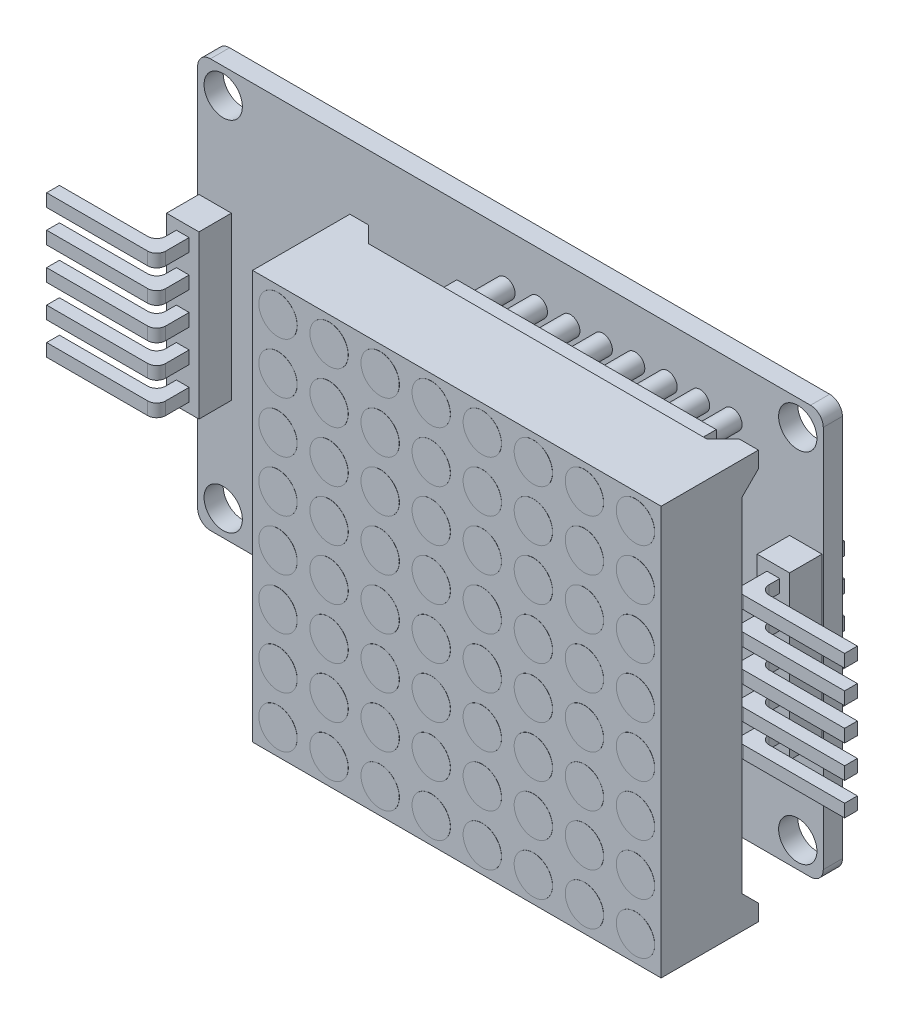
from build123d import *

# Parameters (mm, degrees)
CROQUIS1_R                = 1.5
SALIENTE_EXTRUIR1_DEPTH   = 1.5
CROQUIS2_W                = 2.54
CROQUIS2_H                = 12.7
SALIENTE_EXTRUIR2_DEPTH   = 2.54
CROQUIS3_R                = 0.75
SALIENTE_EXTRUIR3_DEPTH   = 2.54
CROQUIS4_W                = 20.32
CROQUIS4_H                = 2.4
SALIENTE_EXTRUIR4_DEPTH   = 2.54
CROQUIS5_R                = 0.5
CORTAR_EXTRUIR1_DEPTH     = 1.27
SALIENTE_EXTRUIR6_START   = -5.08
CROQUIS6_W                = 1
CROQUIS6_H                = 1
SALIENTE_EXTRUIR6_DEPTH   = 7.62
CROQUIS8_W                = 1
CROQUIS8_H                = 1
SALIENTE_EXTRUIR7_DEPTH   = 7.62
REDONDEO3_R               = 0.7
REDONDEO4_R               = 0.7
REDONDEO5_R               = 0.7
REDONDEO6_R               = 0.7
REDONDEO7_R               = 0.7
REDONDEO8_R               = 0.7
REDONDEO9_R               = 0.7
REDONDEO10_R              = 0.7
REDONDEO11_R              = 0.7
REDONDEO12_R              = 0.7
REDONDEO3_OF_SIMETR_A1_R  = 0.7
REDONDEO4_OF_SIMETR_A1_R  = 0.7
REDONDEO5_OF_SIMETR_A1_R  = 0.7
REDONDEO6_OF_SIMETR_A1_R  = 0.7
REDONDEO7_OF_SIMETR_A1_R  = 0.7
REDONDEO8_OF_SIMETR_A1_R  = 0.7
REDONDEO9_OF_SIMETR_A1_R  = 0.7
REDONDEO10_OF_SIMETR_A1_R = 0.7
REDONDEO11_OF_SIMETR_A1_R = 0.7
REDONDEO12_OF_SIMETR_A1_R = 0.7
CROQUIS11_W               = 32
CROQUIS11_H               = 32
SALIENTE_EXTRUIR8_DEPTH   = 7.62
CROQUIS12_W               = 31.6
CROQUIS12_H               = 31.6
CORTAR_EXTRUIR2_DEPTH     = 5.08
CORTAR_EXTRUIR5_DEPTH     = 0.2
CORTAR_EXTRUIR7_DEPTH     = 2.3
CORTAR_EXTRUIR8_DEPTH     = 2.3
CORTAR_EXTRUIR9_DEPTH     = 2.3
CROQUIS18_R               = 1.5
SALIENTE_EXTRUIR9_DEPTH   = 0.01


with BuildPart() as part:
    # Croquis1 → Saliente-Extruir1 (new body)
    with BuildSketch(Plane.XY):
        with BuildLine():
            Line((-23.5, 16), (23.5, 16))
            ThreePointArc((23.5, 16), (24.207106781, 15.707106781), (24.5, 15))
            Line((24.5, 15), (24.5, -15))
            ThreePointArc((24.5, -15), (24.207106781, -15.707106781), (23.5, -16))
            Line((23.5, -16), (-23.5, -16))
            ThreePointArc((-23.5, -16), (-24.207106781, -15.707106781), (-24.5, -15))
            Line((-24.5, -15), (-24.5, 15))
            ThreePointArc((-24.5, 15), (-24.207106781, 15.707106781), (-23.5, 16))
        make_face()
        with Locations((-22.5, -14)):
            Circle(CROQUIS1_R, mode=Mode.SUBTRACT)
        with Locations((-22.5, 14)):
            Circle(CROQUIS1_R, mode=Mode.SUBTRACT)
        with Locations((22.5, 14)):
            Circle(CROQUIS1_R, mode=Mode.SUBTRACT)
        with Locations((22.5, -14)):
            Circle(CROQUIS1_R, mode=Mode.SUBTRACT)
    extrude(amount=SALIENTE_EXTRUIR1_DEPTH)

    # Croquis2 → Saliente-Extruir2 (add)
    with BuildSketch(Plane.XY.offset(1.5)):
        with Locations((-23.13, 0)):
            Rectangle(CROQUIS2_W, CROQUIS2_H)
        with Locations((23.13, 0)):
            Rectangle(CROQUIS2_W, CROQUIS2_H)
    extrude(amount=SALIENTE_EXTRUIR2_DEPTH)

    # Croquis3 → Saliente-Extruir3 (add, symmetric)
    with BuildSketch(Plane.XY.offset(1.5)):
        with Locations((-0.39, 12)):
            Circle(CROQUIS3_R)
        with Locations((2.15, 12)):
            Circle(CROQUIS3_R)
        with Locations((4.69, 12)):
            Circle(CROQUIS3_R)
        with Locations((7.23, 12)):
            Circle(CROQUIS3_R)
        with Locations((9.77, 12)):
            Circle(CROQUIS3_R)
        with Locations((12.31, 12)):
            Circle(CROQUIS3_R)
        with Locations((14.85, 12)):
            Circle(CROQUIS3_R)
        with Locations((17.39, 12)):
            Circle(CROQUIS3_R)
        with Locations((17.39, -12)):
            Circle(CROQUIS3_R)
        with Locations((14.85, -12)):
            Circle(CROQUIS3_R)
        with Locations((12.31, -12)):
            Circle(CROQUIS3_R)
        with Locations((9.77, -12)):
            Circle(CROQUIS3_R)
        with Locations((7.23, -12)):
            Circle(CROQUIS3_R)
        with Locations((4.69, -12)):
            Circle(CROQUIS3_R)
        with Locations((2.15, -12)):
            Circle(CROQUIS3_R)
        with Locations((-0.39, -12)):
            Circle(CROQUIS3_R)
    extrude(amount=SALIENTE_EXTRUIR3_DEPTH, both=True)

    # Croquis4 → Saliente-Extruir4 (add)
    with BuildSketch(Plane.XY.offset(4.04)):
        with Locations((8.5, 12)):
            Rectangle(CROQUIS4_W, CROQUIS4_H)
        with Locations((8.5, -12)):
            Rectangle(CROQUIS4_W, CROQUIS4_H)
    extrude(amount=SALIENTE_EXTRUIR4_DEPTH)

    # Croquis5 → Cortar-Extruir1 (cut)
    with BuildSketch(Plane.XY.offset(6.58)):
        with Locations((-0.39, 12)):
            Circle(CROQUIS5_R)
        with Locations((2.15, 12)):
            Circle(CROQUIS5_R)
        with Locations((4.69, 12)):
            Circle(CROQUIS5_R)
        with Locations((7.23, 12)):
            Circle(CROQUIS5_R)
        with Locations((9.77, 12)):
            Circle(CROQUIS5_R)
        with Locations((12.31, 12)):
            Circle(CROQUIS5_R)
        with Locations((14.85, 12)):
            Circle(CROQUIS5_R)
        with Locations((17.39, 12)):
            Circle(CROQUIS5_R)
        with Locations((17.39, -12)):
            Circle(CROQUIS5_R)
        with Locations((14.85, -12)):
            Circle(CROQUIS5_R)
        with Locations((12.31, -12)):
            Circle(CROQUIS5_R)
        with Locations((9.77, -12)):
            Circle(CROQUIS5_R)
        with Locations((7.23, -12)):
            Circle(CROQUIS5_R)
        with Locations((4.69, -12)):
            Circle(CROQUIS5_R)
        with Locations((2.15, -12)):
            Circle(CROQUIS5_R)
        with Locations((-0.39, -12)):
            Circle(CROQUIS5_R)
    extrude(amount=-CORTAR_EXTRUIR1_DEPTH, mode=Mode.SUBTRACT)

    # Croquis6 → Saliente-Extruir6 (add)
    with BuildSketch(Plane.XY.offset(4.04).offset(SALIENTE_EXTRUIR6_START)):
        with Locations((-23.13, 5.08)):
            Rectangle(CROQUIS6_W, CROQUIS6_H)
        with Locations((-23.13, 2.54)):
            Rectangle(CROQUIS6_W, CROQUIS6_H)
        with Locations((-23.13, 0)):
            Rectangle(CROQUIS6_W, CROQUIS6_H)
        with Locations((-23.13, -2.54)):
            Rectangle(CROQUIS6_W, CROQUIS6_H)
        with Locations((-23.13, -5.08)):
            Rectangle(CROQUIS6_W, CROQUIS6_H)
    saliente_extruir6 = extrude(amount=SALIENTE_EXTRUIR6_DEPTH)

    # Croquis8 → Saliente-Extruir7 (add)
    with BuildSketch(Plane.ZY.offset(23.63)):
        with Locations((6.08, 5.08)):
            Rectangle(CROQUIS8_W, CROQUIS8_H)
        with Locations((6.08, 2.54)):
            Rectangle(CROQUIS8_W, CROQUIS8_H)
        with Locations((6.08, 0)):
            Rectangle(CROQUIS8_W, CROQUIS8_H)
        with Locations((6.08, -2.54)):
            Rectangle(CROQUIS8_W, CROQUIS8_H)
        with Locations((6.08, -5.08)):
            Rectangle(CROQUIS8_W, CROQUIS8_H)
    saliente_extruir7 = extrude(amount=SALIENTE_EXTRUIR7_DEPTH)

    # Redondeo3
    redondeo3_edges = [part.edges().sort_by_distance(p)[0] for p in [
        (-22.63, -5.08, 6.58),
    ]]
    fillet(redondeo3_edges, radius=REDONDEO3_R)

    # Redondeo4
    redondeo4_edges = [part.edges().sort_by_distance(p)[0] for p in [
        (-22.63, 0, 6.58),
    ]]
    fillet(redondeo4_edges, radius=REDONDEO4_R)

    # Redondeo5
    redondeo5_edges = [part.edges().sort_by_distance(p)[0] for p in [
        (-22.63, -2.54, 6.58),
    ]]
    fillet(redondeo5_edges, radius=REDONDEO5_R)

    # Redondeo6
    redondeo6_edges = [part.edges().sort_by_distance(p)[0] for p in [
        (-22.63, 2.54, 6.58),
    ]]
    fillet(redondeo6_edges, radius=REDONDEO6_R)

    # Redondeo7
    redondeo7_edges = [part.edges().sort_by_distance(p)[0] for p in [
        (-22.63, 5.08, 6.58),
    ]]
    fillet(redondeo7_edges, radius=REDONDEO7_R)

    # Redondeo8
    redondeo8_edges = [part.edges().sort_by_distance(p)[0] for p in [
        (-23.63, -5.08, 5.58),
    ]]
    fillet(redondeo8_edges, radius=REDONDEO8_R)

    # Redondeo9
    redondeo9_edges = [part.edges().sort_by_distance(p)[0] for p in [
        (-23.63, -2.54, 5.58),
    ]]
    fillet(redondeo9_edges, radius=REDONDEO9_R)

    # Redondeo10
    redondeo10_edges = [part.edges().sort_by_distance(p)[0] for p in [
        (-23.63, 0, 5.58),
    ]]
    fillet(redondeo10_edges, radius=REDONDEO10_R)

    # Redondeo11
    redondeo11_edges = [part.edges().sort_by_distance(p)[0] for p in [
        (-23.63, 2.54, 5.58),
    ]]
    fillet(redondeo11_edges, radius=REDONDEO11_R)

    # Redondeo12
    redondeo12_edges = [part.edges().sort_by_distance(p)[0] for p in [
        (-23.63, 5.08, 5.58),
    ]]
    fillet(redondeo12_edges, radius=REDONDEO12_R)

    # Simetría1: Saliente-Extruir6, Saliente-Extruir7 across plane
    add(saliente_extruir6.mirror(Plane(origin=(0, 0, 0), x_dir=(0, 0, 1), z_dir=(1, 0, 0))))
    add(saliente_extruir7.mirror(Plane(origin=(0, 0, 0), x_dir=(0, 0, 1), z_dir=(1, 0, 0))))

    # Redondeo3 of Simetría1
    redondeo3_of_simetr_a1_edges = [part.edges().sort_by_distance(p)[0] for p in [
        (22.63, -5.08, 6.58),
    ]]
    fillet(redondeo3_of_simetr_a1_edges, radius=REDONDEO3_OF_SIMETR_A1_R)

    # Redondeo4 of Simetría1
    redondeo4_of_simetr_a1_edges = [part.edges().sort_by_distance(p)[0] for p in [
        (22.63, 0, 6.58),
    ]]
    fillet(redondeo4_of_simetr_a1_edges, radius=REDONDEO4_OF_SIMETR_A1_R)

    # Redondeo5 of Simetría1
    redondeo5_of_simetr_a1_edges = [part.edges().sort_by_distance(p)[0] for p in [
        (22.63, -2.54, 6.58),
    ]]
    fillet(redondeo5_of_simetr_a1_edges, radius=REDONDEO5_OF_SIMETR_A1_R)

    # Redondeo6 of Simetría1
    redondeo6_of_simetr_a1_edges = [part.edges().sort_by_distance(p)[0] for p in [
        (22.63, 2.54, 6.58),
    ]]
    fillet(redondeo6_of_simetr_a1_edges, radius=REDONDEO6_OF_SIMETR_A1_R)

    # Redondeo7 of Simetría1
    redondeo7_of_simetr_a1_edges = [part.edges().sort_by_distance(p)[0] for p in [
        (22.63, 5.08, 6.58),
    ]]
    fillet(redondeo7_of_simetr_a1_edges, radius=REDONDEO7_OF_SIMETR_A1_R)

    # Redondeo8 of Simetría1
    redondeo8_of_simetr_a1_edges = [part.edges().sort_by_distance(p)[0] for p in [
        (23.63, -5.08, 5.58),
    ]]
    fillet(redondeo8_of_simetr_a1_edges, radius=REDONDEO8_OF_SIMETR_A1_R)

    # Redondeo9 of Simetría1
    redondeo9_of_simetr_a1_edges = [part.edges().sort_by_distance(p)[0] for p in [
        (23.63, -2.54, 5.58),
    ]]
    fillet(redondeo9_of_simetr_a1_edges, radius=REDONDEO9_OF_SIMETR_A1_R)

    # Redondeo10 of Simetría1
    redondeo10_of_simetr_a1_edges = [part.edges().sort_by_distance(p)[0] for p in [
        (23.63, 0, 5.58),
    ]]
    fillet(redondeo10_of_simetr_a1_edges, radius=REDONDEO10_OF_SIMETR_A1_R)

    # Redondeo11 of Simetría1
    redondeo11_of_simetr_a1_edges = [part.edges().sort_by_distance(p)[0] for p in [
        (23.63, 2.54, 5.58),
    ]]
    fillet(redondeo11_of_simetr_a1_edges, radius=REDONDEO11_OF_SIMETR_A1_R)

    # Redondeo12 of Simetría1
    redondeo12_of_simetr_a1_edges = [part.edges().sort_by_distance(p)[0] for p in [
        (23.63, 5.08, 5.58),
    ]]
    fillet(redondeo12_of_simetr_a1_edges, radius=REDONDEO12_OF_SIMETR_A1_R)

    # Croquis11 → Saliente-Extruir8 (add)
    with BuildSketch(Plane.XY.offset(6.58)):
        with Locations((8.5, 0)):
            Rectangle(CROQUIS11_W, CROQUIS11_H)
    extrude(amount=SALIENTE_EXTRUIR8_DEPTH)

    # Croquis12 → Cortar-Extruir2 (cut)
    with BuildSketch(Plane(origin=(0, 0, 6.58), x_dir=(-1, 0, 0), z_dir=(0, 0, -1))):
        with Locations((-8.5, 0)):
            Rectangle(CROQUIS12_W, CROQUIS12_H)
    extrude(amount=-CORTAR_EXTRUIR2_DEPTH, mode=Mode.SUBTRACT)

    # Croquis14 → Cortar-Extruir5 (cut)
    with BuildSketch(Plane(origin=(0, -15.8, 0), x_dir=(1, 0, 0), z_dir=(0, 1, 0))):
        Polygon((23.23, -6.58), (21.96, -7.85), (-4.96, -7.85), (-6.23, -6.58), align=None)
    extrude(amount=-CORTAR_EXTRUIR5_DEPTH, mode=Mode.SUBTRACT)

    # Croquis15 → Cortar-Extruir7 (cut)
    with BuildSketch(Plane.ZY.offset(-24.3)):
        Polygon((6.58, -14.73), (7.85, -13.46), (7.85, 13.46), (6.58, 14.73), align=None)
    extrude(amount=-CORTAR_EXTRUIR7_DEPTH, mode=Mode.SUBTRACT)

    # Croquis16 → Cortar-Extruir8 (cut)
    with BuildSketch(Plane.XZ.offset(-15.8)):
        Polygon((-6.03, 6.58), (-4.76, 7.85), (21.76, 7.85), (23.03, 6.58), align=None)
    extrude(amount=-CORTAR_EXTRUIR8_DEPTH, mode=Mode.SUBTRACT)

    # Croquis17 → Cortar-Extruir9 (cut)
    with BuildSketch(Plane(origin=(-7.3, 0, 0), x_dir=(0, 0, -1), z_dir=(1, 0, 0))):
        Polygon((-6.58, -14.53), (-7.85, -13.26), (-7.85, 13.26), (-6.58, 14.53), align=None)
    extrude(amount=-CORTAR_EXTRUIR9_DEPTH, mode=Mode.SUBTRACT)

    # Croquis18 → Saliente-Extruir9 (add)
    with BuildSketch(Plane.XY.offset(14.2)):
        with Locations((-5.5, -14)):
            Circle(CROQUIS18_R)
        with Locations((-1.5, -14)):
            Circle(CROQUIS18_R)
        with Locations((2.5, -14)):
            Circle(CROQUIS18_R)
        with Locations((6.5, -14)):
            Circle(CROQUIS18_R)
        with Locations((10.5, -14)):
            Circle(CROQUIS18_R)
        with Locations((14.5, -14)):
            Circle(CROQUIS18_R)
        with Locations((18.5, -14)):
            Circle(CROQUIS18_R)
        with Locations((22.5, -14)):
            Circle(CROQUIS18_R)
        with Locations((-1.5, -10)):
            Circle(CROQUIS18_R)
        with Locations((2.5, -10)):
            Circle(CROQUIS18_R)
        with Locations((6.5, -10)):
            Circle(CROQUIS18_R)
        with Locations((10.5, -10)):
            Circle(CROQUIS18_R)
        with Locations((14.5, -10)):
            Circle(CROQUIS18_R)
        with Locations((18.5, -10)):
            Circle(CROQUIS18_R)
        with Locations((22.5, -10)):
            Circle(CROQUIS18_R)
        with Locations((-1.5, -6)):
            Circle(CROQUIS18_R)
        with Locations((2.5, -6)):
            Circle(CROQUIS18_R)
        with Locations((6.5, -6)):
            Circle(CROQUIS18_R)
        with Locations((10.5, -6)):
            Circle(CROQUIS18_R)
        with Locations((14.5, -6)):
            Circle(CROQUIS18_R)
        with Locations((18.5, -6)):
            Circle(CROQUIS18_R)
        with Locations((22.5, -6)):
            Circle(CROQUIS18_R)
        with Locations((-1.5, -2)):
            Circle(CROQUIS18_R)
        with Locations((2.5, -2)):
            Circle(CROQUIS18_R)
        with Locations((6.5, -2)):
            Circle(CROQUIS18_R)
        with Locations((10.5, -2)):
            Circle(CROQUIS18_R)
        with Locations((14.5, -2)):
            Circle(CROQUIS18_R)
        with Locations((18.5, -2)):
            Circle(CROQUIS18_R)
        with Locations((22.5, -2)):
            Circle(CROQUIS18_R)
        with Locations((-1.5, 2)):
            Circle(CROQUIS18_R)
        with Locations((2.5, 2)):
            Circle(CROQUIS18_R)
        with Locations((6.5, 2)):
            Circle(CROQUIS18_R)
        with Locations((10.5, 2)):
            Circle(CROQUIS18_R)
        with Locations((14.5, 2)):
            Circle(CROQUIS18_R)
        with Locations((18.5, 2)):
            Circle(CROQUIS18_R)
        with Locations((22.5, 2)):
            Circle(CROQUIS18_R)
        with Locations((-1.5, 6)):
            Circle(CROQUIS18_R)
        with Locations((2.5, 6)):
            Circle(CROQUIS18_R)
        with Locations((6.5, 6)):
            Circle(CROQUIS18_R)
        with Locations((10.5, 6)):
            Circle(CROQUIS18_R)
        with Locations((14.5, 6)):
            Circle(CROQUIS18_R)
        with Locations((18.5, 6)):
            Circle(CROQUIS18_R)
        with Locations((22.5, 6)):
            Circle(CROQUIS18_R)
        with Locations((-1.5, 10)):
            Circle(CROQUIS18_R)
        with Locations((2.5, 10)):
            Circle(CROQUIS18_R)
        with Locations((6.5, 10)):
            Circle(CROQUIS18_R)
        with Locations((10.5, 10)):
            Circle(CROQUIS18_R)
        with Locations((14.5, 10)):
            Circle(CROQUIS18_R)
        with Locations((18.5, 10)):
            Circle(CROQUIS18_R)
        with Locations((22.5, 10)):
            Circle(CROQUIS18_R)
        with Locations((-1.5, 14)):
            Circle(CROQUIS18_R)
        with Locations((2.5, 14)):
            Circle(CROQUIS18_R)
        with Locations((6.5, 14)):
            Circle(CROQUIS18_R)
        with Locations((10.5, 14)):
            Circle(CROQUIS18_R)
        with Locations((14.5, 14)):
            Circle(CROQUIS18_R)
        with Locations((18.5, 14)):
            Circle(CROQUIS18_R)
        with Locations((22.5, 14)):
            Circle(CROQUIS18_R)
        with Locations((-5.5, -10)):
            Circle(CROQUIS18_R)
        with Locations((-5.5, -6)):
            Circle(CROQUIS18_R)
        with Locations((-5.5, -2)):
            Circle(CROQUIS18_R)
        with Locations((-5.5, 2)):
            Circle(CROQUIS18_R)
        with Locations((-5.5, 6)):
            Circle(CROQUIS18_R)
        with Locations((-5.5, 10)):
            Circle(CROQUIS18_R)
        with Locations((-5.5, 14)):
            Circle(CROQUIS18_R)
    extrude(amount=SALIENTE_EXTRUIR9_DEPTH)


solid = part.part
